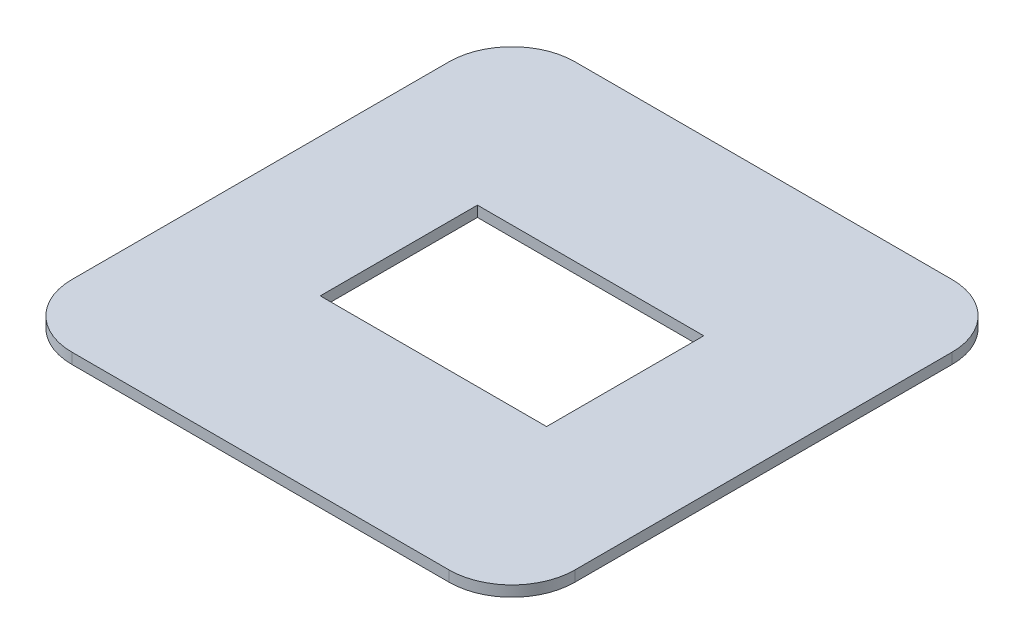
from build123d import *

# Parameters (mm, degrees)
ESQUISSE1_W        = 80
ESQUISSE1_H        = 80
ESQUISSE1_W_2      = 36
ESQUISSE1_H_2      = 25
BOSS_EXTRU_1_DEPTH = 1.7
CONG_1_R           = 10


with BuildPart() as part:
    # Esquisse1 → Boss.-Extru.1 (new body)
    with BuildSketch(Plane(origin=(0, 0, 0), x_dir=(1, 0, 0), z_dir=(0, 1, 0))):
        Rectangle(ESQUISSE1_W, ESQUISSE1_H)
        Rectangle(ESQUISSE1_W_2, ESQUISSE1_H_2, mode=Mode.SUBTRACT)
    extrude(amount=BOSS_EXTRU_1_DEPTH)

    # Congé1
    cong_1_edges = [part.edges().sort_by_distance(p)[0] for p in [
        (-40, 0.85, -40),
        (-40, 0.85, 40),
        (40, 0.85, 40),
        (40, 0.85, -40),
    ]]
    fillet(cong_1_edges, radius=CONG_1_R)


solid = part.part
